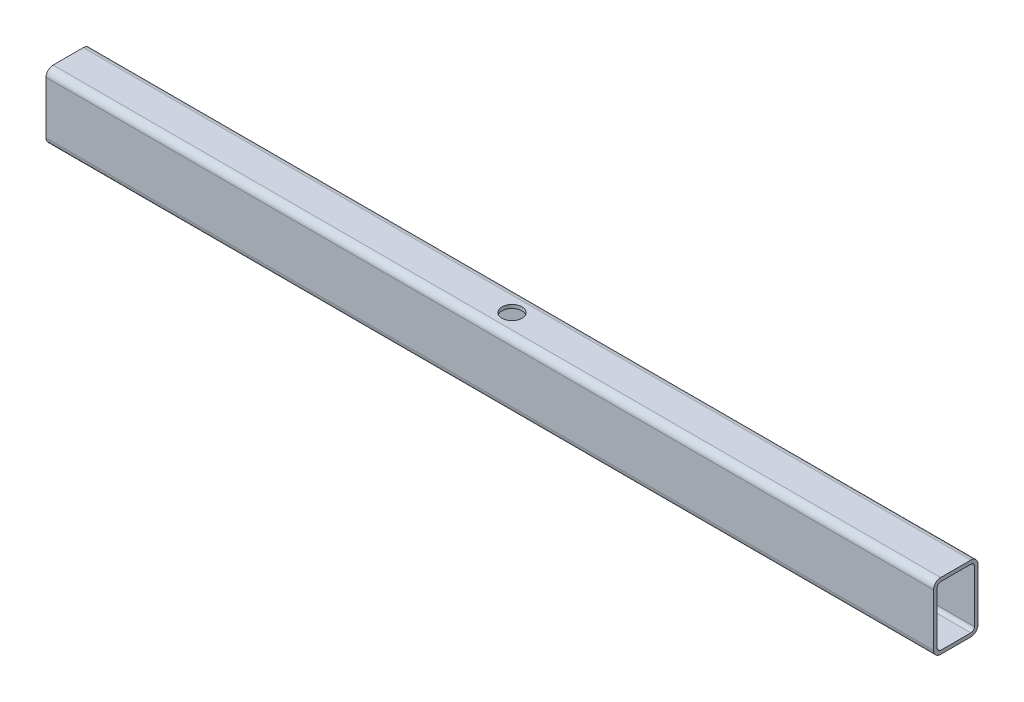
from build123d import *

# Parameters (mm, degrees)
DIKD_RTGEN_T_P_60_X_40_X_3_2_1_DEPTH = 800
IZIM3_R                              = 9
KES_EKSTR_ZYON1_DEPTH                = 50
SCALE1_SCALE                         = 0.25


with BuildPart() as part:
    # Sketch1 → Dikdörtgen tüp 60 X 40 X 3.2(1) (new body)
    with BuildSketch(Plane(origin=(0, 0, 0), x_dir=(0, 0, -1), z_dir=(1, 0, 0))):
        with BuildLine():
            Line((-13.6, -30), (13.6, -30))
            ThreePointArc((13.6, -30), (18.1254834, -28.1254834), (20, -23.6))
            Line((20, -23.6), (20, 23.6))
            ThreePointArc((20, 23.6), (18.1254834, 28.1254834), (13.6, 30))
            Line((13.6, 30), (-13.6, 30))
            ThreePointArc((-13.6, 30), (-18.1254834, 28.1254834), (-20, 23.6))
            Line((-20, 23.6), (-20, -23.6))
            ThreePointArc((-20, -23.6), (-18.1254834, -28.1254834), (-13.6, -30))
        make_face()
        with BuildLine():
            Line((-13.6, -26.8), (13.6, -26.8))
            ThreePointArc((13.6, -26.8), (15.8627417, -25.8627417), (16.8, -23.6))
            Line((16.8, -23.6), (16.8, 23.6))
            ThreePointArc((16.8, 23.6), (15.8627417, 25.8627417), (13.6, 26.8))
            Line((13.6, 26.8), (-13.6, 26.8))
            ThreePointArc((-13.6, 26.8), (-15.8627417, 25.8627417), (-16.8, 23.6))
            Line((-16.8, 23.6), (-16.8, -23.6))
            ThreePointArc((-16.8, -23.6), (-15.8627417, -25.8627417), (-13.6, -26.8))
        make_face(mode=Mode.SUBTRACT)
    extrude(amount=DIKD_RTGEN_T_P_60_X_40_X_3_2_1_DEPTH)

    # Çizim3 → Kes-Ekstrüzyon1 (cut, symmetric)
    with BuildSketch(Plane(origin=(0, 0, 0), x_dir=(1, 0, 0), z_dir=(0, 1, 0))):
        with Locations(Location((400, 0, 0), (0, 0, 270))):
            Circle(IZIM3_R)
    extrude(amount=KES_EKSTR_ZYON1_DEPTH, both=True, mode=Mode.SUBTRACT)


with BuildPart() as part_1:
    # Scale1: scaled about (0, 0, 0)
    add(part.part.scale(SCALE1_SCALE))


solid = part_1.part
